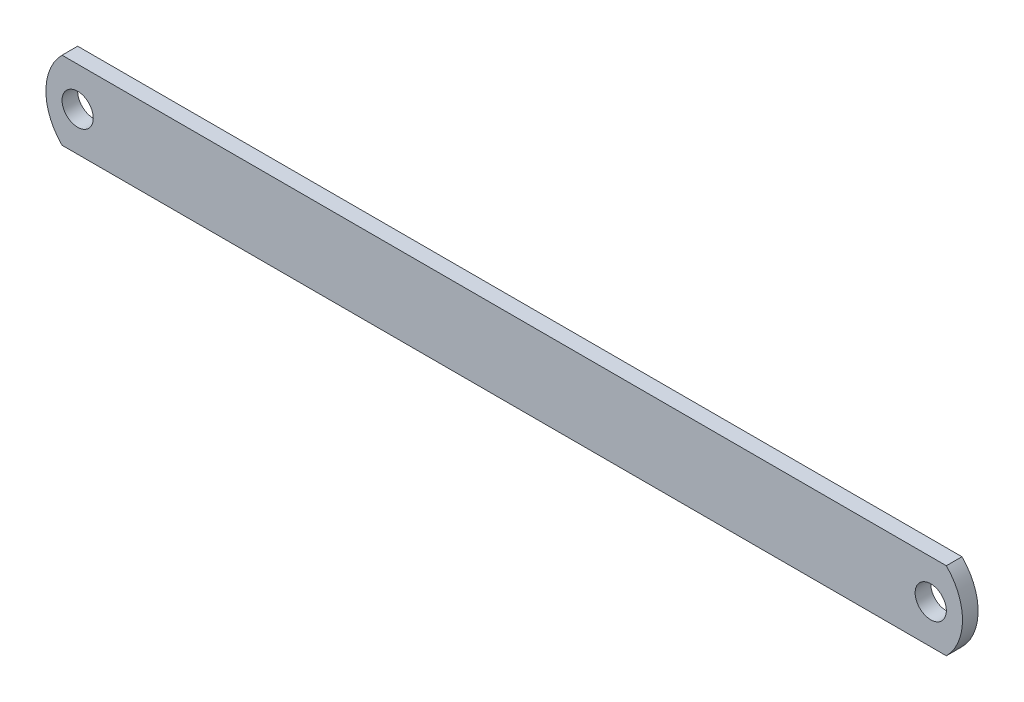
from build123d import *

# Parameters (mm, degrees)
BOSS_EXTRUDE1_DEPTH = 3
SKETCH2_R           = 3
CUT_EXTRUDE1_DEPTH  = 10
SKETCH3_R           = 3
CUT_EXTRUDE2_DEPTH  = 10


with BuildPart() as part:
    # Sketch1 → Boss-Extrude1 (new body)
    with BuildSketch(Plane.XY):
        with BuildLine():
            Line((0, 0), (170, 0))
            ThreePointArc((170, 0), (173.106601718, -7.5), (170, -15))
            Line((170, -15), (0, -15))
            ThreePointArc((0, -15), (-3.106601718, -7.5), (0, 0))
        make_face()
    extrude(amount=BOSS_EXTRUDE1_DEPTH)

    # Sketch2 → Cut-Extrude1 (cut)
    with BuildSketch(Plane.XY.offset(3)):
        with Locations((3, -7.5)):
            Circle(SKETCH2_R)
    extrude(amount=-CUT_EXTRUDE1_DEPTH, mode=Mode.SUBTRACT)

    # Sketch3 → Cut-Extrude2 (cut)
    with BuildSketch(Plane.XY.offset(3)):
        with Locations((167, -7.5)):
            Circle(SKETCH3_R)
    extrude(amount=-CUT_EXTRUDE2_DEPTH, mode=Mode.SUBTRACT)


solid = part.part
